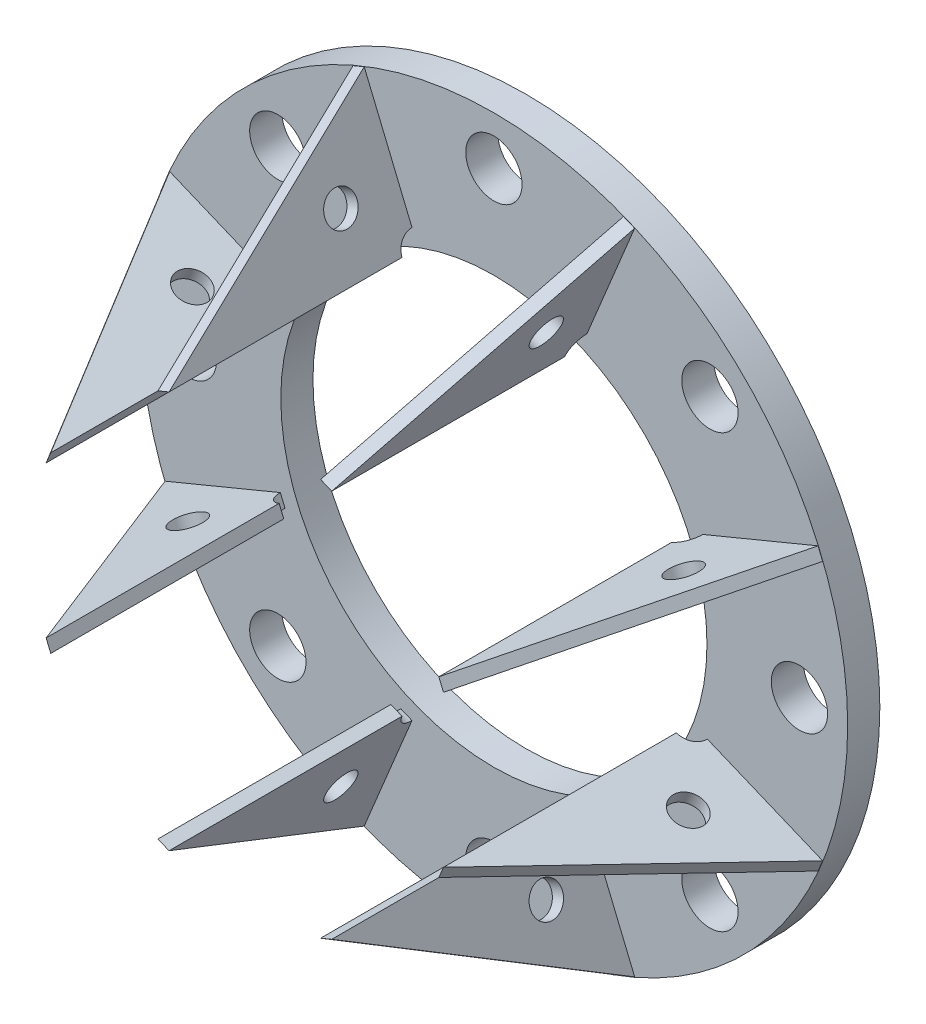
from build123d import *

# Parameters (mm, degrees)
SKETCH1_R         = 139.7
SKETCH1_R_2       = 84.1375
EXTRUDE1_DEPTH    = 12.7
CIRPATTERN2_COUNT = 8
EXTRUDE4_DEPTH    = 98.345625
SKETCH8_R         = 6.35
EXTRUDE5_DEPTH    = 4.7625
CIRPATTERN4_COUNT = 8


with BuildPart() as part:
    # Sketch1 → Extrude1 (new body)
    with BuildSketch(Plane.XY):
        Circle(SKETCH1_R)
        Circle(SKETCH1_R_2, mode=Mode.SUBTRACT)
    extrude(amount=EXTRUDE1_DEPTH)

    # Sketch2 → 0.625_ Diameter Hole1 (revolve, cut)
    with BuildSketch(Plane(origin=(0, 120.65, 12.7), x_dir=(0, -1, 0), z_dir=(1, 0, 0))):
        Polygon((0, 0), (0, 32.077063629), (11.1125, 25.4), (11.1125, 0), align=None)
    f_0_625_diameter_hole1 = revolve(axis=Axis((0, 120.65, 19.05), (0, 0, -1)), mode=Mode.SUBTRACT)

    # CirPattern2: 0.625_ Diameter Hole1 ×8 about axis
    cirpattern2_axis = Axis((0, 0, 0), (0, 0, 1))
    for i in range(1, CIRPATTERN2_COUNT):
        add(f_0_625_diameter_hole1.rotate(cirpattern2_axis, i * 360 / CIRPATTERN2_COUNT), mode=Mode.SUBTRACT)

    # Sketch6 → Extrude4 (add)
    with BuildSketch(Plane.XY.offset(12.7)):
        Polygon((-55.596678696, 127.999749611), (-34.313207501, 76.616904797), (-29.913231227, 78.439434644), (-51.196702422, 129.822279457), align=None)
    extrude4 = extrude(amount=EXTRUDE4_DEPTH)

    # Sketch8 → Extrude5 (cut)
    with BuildSketch(Plane(origin=(2.199988137, 0.911264923, 0), x_dir=(0, 0, -1), z_dir=(0.923879533, 0.382683432, 0))):
        with Locations((-34.755447715, 105.971333923)):
            Circle(SKETCH8_R)
        Polygon((-12.7, 139.532276663), (-111.045625, 83.915886208), (-111.045625, 139.532276663), align=None)
        with BuildLine():
            Line((-12.7, 90.265886208), (-12.7, 83.915886208))
            Line((-12.7, 83.915886208), (-19.05, 83.915886208))
            ThreePointArc((-19.05, 83.915886208), (-17.190128061, 88.406014269), (-12.7, 90.265886208))
        make_face()
    extrude5 = extrude(amount=-EXTRUDE5_DEPTH, mode=Mode.SUBTRACT)

    # CirPattern4: Extrude4, Extrude5 ×8 about axis
    cirpattern4_axis = Axis((0, 0, 0), (0, 0, 1))
    for i in range(1, CIRPATTERN4_COUNT):
        add(extrude4.rotate(cirpattern4_axis, i * 360 / CIRPATTERN4_COUNT))
        add(extrude5.rotate(cirpattern4_axis, i * 360 / CIRPATTERN4_COUNT), mode=Mode.SUBTRACT)


solid = part.part
